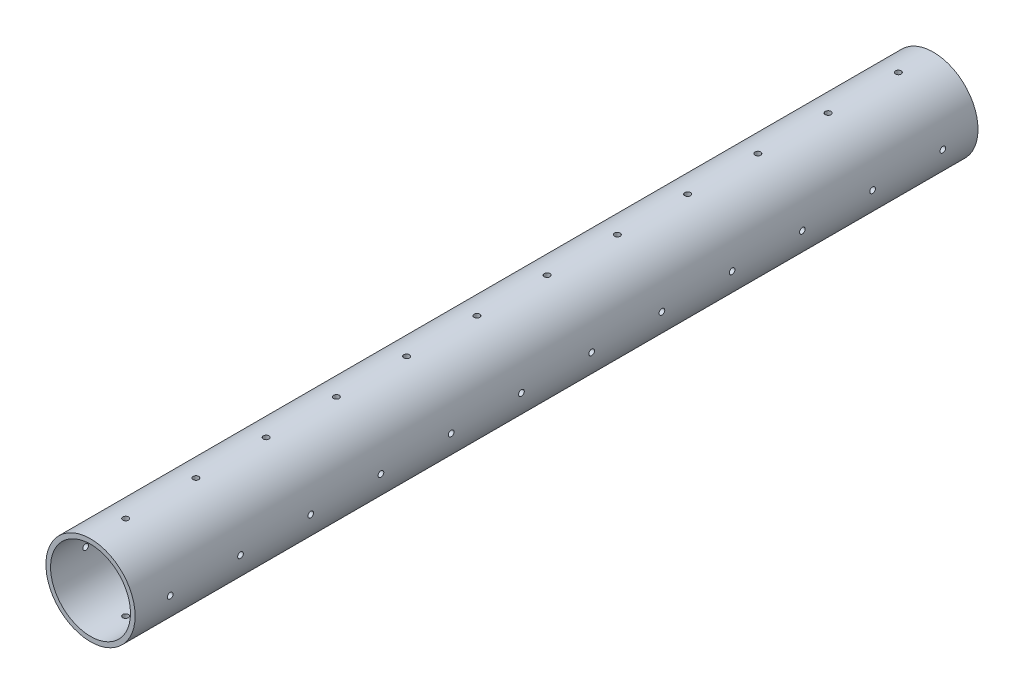
from build123d import *

# Parameters (mm, degrees)
SKETCH1_R                           = 15.875
SKETCH1_R_2                         = 14.224
BOSS_EXTRUDE1_DEPTH                 = 300
CUT_EXTRUDE1_REACH                  = 302.839
CUT_EXTRUDE1_END_RADIUS             = 15.875
SKETCH2_R                           = 1.0125
CUT_EXTRUDE1_DIRECTION_2_REACH      = 302.839
CUT_EXTRUDE1_DIRECTION_2_END_RADIUS = 15.875
CUT_EXTRUDE2_REACH                  = 302.839
CUT_EXTRUDE2_END_RADIUS             = 15.875
SKETCH3_R                           = 1.0125
CUT_EXTRUDE2_DIRECTION_2_REACH      = 302.839
CUT_EXTRUDE2_DIRECTION_2_END_RADIUS = 15.875


with BuildPart() as part:
    # Sketch1 → Boss-Extrude1 (new body)
    with BuildSketch(Plane.XY):
        Circle(SKETCH1_R)
        Circle(SKETCH1_R_2, mode=Mode.SUBTRACT)
    extrude(amount=BOSS_EXTRUDE1_DEPTH)

    # Cut-Extrude1: up to this cylinder (the profile starts inside it)
    cut_extrude1_end = Plane(origin=(0, 0, 150), z_dir=(0, 0, -1)) * Cylinder(CUT_EXTRUDE1_END_RADIUS, 913.428, mode=Mode.PRIVATE)
    # Sketch2 → Cut-Extrude1 (cut, up to the surface)
    with BuildSketch(Plane(origin=(0, 0, 0), x_dir=(1, 0, 0), z_dir=(0, 1, 0)), mode=Mode.PRIVATE) as cut_extrude1_sk1:
        with Locations((0, -12.5)):
            Circle(SKETCH2_R)
    cut_extrude1_tool1 = extrude(cut_extrude1_sk1.sketch, amount=-CUT_EXTRUDE1_REACH, mode=Mode.PRIVATE) & cut_extrude1_end
    add(cut_extrude1_tool1.solids().sort_by_distance((0, 0, 12.5))[0], mode=Mode.SUBTRACT)
    # Sketch2 → Cut-Extrude1 (cut, up to the surface)
    with BuildSketch(Plane(origin=(0, 0, 0), x_dir=(1, 0, 0), z_dir=(0, 1, 0)), mode=Mode.PRIVATE) as cut_extrude1_sk2:
        with Locations((0, -37.5)):
            Circle(SKETCH2_R)
    cut_extrude1_tool2 = extrude(cut_extrude1_sk2.sketch, amount=-CUT_EXTRUDE1_REACH, mode=Mode.PRIVATE) & cut_extrude1_end
    add(cut_extrude1_tool2.solids().sort_by_distance((0, 0, 37.5))[0], mode=Mode.SUBTRACT)
    # Sketch2 → Cut-Extrude1 (cut, up to the surface)
    with BuildSketch(Plane(origin=(0, 0, 0), x_dir=(1, 0, 0), z_dir=(0, 1, 0)), mode=Mode.PRIVATE) as cut_extrude1_sk3:
        with Locations((0, -62.5)):
            Circle(SKETCH2_R)
    cut_extrude1_tool3 = extrude(cut_extrude1_sk3.sketch, amount=-CUT_EXTRUDE1_REACH, mode=Mode.PRIVATE) & cut_extrude1_end
    add(cut_extrude1_tool3.solids().sort_by_distance((0, 0, 62.5))[0], mode=Mode.SUBTRACT)
    # Sketch2 → Cut-Extrude1 (cut, up to the surface)
    with BuildSketch(Plane(origin=(0, 0, 0), x_dir=(1, 0, 0), z_dir=(0, 1, 0)), mode=Mode.PRIVATE) as cut_extrude1_sk4:
        with Locations((0, -87.5)):
            Circle(SKETCH2_R)
    cut_extrude1_tool4 = extrude(cut_extrude1_sk4.sketch, amount=-CUT_EXTRUDE1_REACH, mode=Mode.PRIVATE) & cut_extrude1_end
    add(cut_extrude1_tool4.solids().sort_by_distance((0, 0, 87.5))[0], mode=Mode.SUBTRACT)
    # Sketch2 → Cut-Extrude1 (cut, up to the surface)
    with BuildSketch(Plane(origin=(0, 0, 0), x_dir=(1, 0, 0), z_dir=(0, 1, 0)), mode=Mode.PRIVATE) as cut_extrude1_sk5:
        with Locations((0, -112.5)):
            Circle(SKETCH2_R)
    cut_extrude1_tool5 = extrude(cut_extrude1_sk5.sketch, amount=-CUT_EXTRUDE1_REACH, mode=Mode.PRIVATE) & cut_extrude1_end
    add(cut_extrude1_tool5.solids().sort_by_distance((0, 0, 112.5))[0], mode=Mode.SUBTRACT)
    # Sketch2 → Cut-Extrude1 (cut, up to the surface)
    with BuildSketch(Plane(origin=(0, 0, 0), x_dir=(1, 0, 0), z_dir=(0, 1, 0)), mode=Mode.PRIVATE) as cut_extrude1_sk6:
        with Locations((0, -137.5)):
            Circle(SKETCH2_R)
    cut_extrude1_tool6 = extrude(cut_extrude1_sk6.sketch, amount=-CUT_EXTRUDE1_REACH, mode=Mode.PRIVATE) & cut_extrude1_end
    add(cut_extrude1_tool6.solids().sort_by_distance((0, 0, 137.5))[0], mode=Mode.SUBTRACT)
    # Sketch2 → Cut-Extrude1 (cut, up to the surface)
    with BuildSketch(Plane(origin=(0, 0, 0), x_dir=(1, 0, 0), z_dir=(0, 1, 0)), mode=Mode.PRIVATE) as cut_extrude1_sk7:
        with Locations((0, -162.5)):
            Circle(SKETCH2_R)
    cut_extrude1_tool7 = extrude(cut_extrude1_sk7.sketch, amount=-CUT_EXTRUDE1_REACH, mode=Mode.PRIVATE) & cut_extrude1_end
    add(cut_extrude1_tool7.solids().sort_by_distance((0, 0, 162.5))[0], mode=Mode.SUBTRACT)
    # Sketch2 → Cut-Extrude1 (cut, up to the surface)
    with BuildSketch(Plane(origin=(0, 0, 0), x_dir=(1, 0, 0), z_dir=(0, 1, 0)), mode=Mode.PRIVATE) as cut_extrude1_sk8:
        with Locations((0, -187.5)):
            Circle(SKETCH2_R)
    cut_extrude1_tool8 = extrude(cut_extrude1_sk8.sketch, amount=-CUT_EXTRUDE1_REACH, mode=Mode.PRIVATE) & cut_extrude1_end
    add(cut_extrude1_tool8.solids().sort_by_distance((0, 0, 187.5))[0], mode=Mode.SUBTRACT)
    # Sketch2 → Cut-Extrude1 (cut, up to the surface)
    with BuildSketch(Plane(origin=(0, 0, 0), x_dir=(1, 0, 0), z_dir=(0, 1, 0)), mode=Mode.PRIVATE) as cut_extrude1_sk9:
        with Locations((0, -212.5)):
            Circle(SKETCH2_R)
    cut_extrude1_tool9 = extrude(cut_extrude1_sk9.sketch, amount=-CUT_EXTRUDE1_REACH, mode=Mode.PRIVATE) & cut_extrude1_end
    add(cut_extrude1_tool9.solids().sort_by_distance((0, 0, 212.5))[0], mode=Mode.SUBTRACT)
    # Sketch2 → Cut-Extrude1 (cut, up to the surface)
    with BuildSketch(Plane(origin=(0, 0, 0), x_dir=(1, 0, 0), z_dir=(0, 1, 0)), mode=Mode.PRIVATE) as cut_extrude1_sk10:
        with Locations((0, -237.5)):
            Circle(SKETCH2_R)
    cut_extrude1_tool10 = extrude(cut_extrude1_sk10.sketch, amount=-CUT_EXTRUDE1_REACH, mode=Mode.PRIVATE) & cut_extrude1_end
    add(cut_extrude1_tool10.solids().sort_by_distance((0, 0, 237.5))[0], mode=Mode.SUBTRACT)
    # Sketch2 → Cut-Extrude1 (cut, up to the surface)
    with BuildSketch(Plane(origin=(0, 0, 0), x_dir=(1, 0, 0), z_dir=(0, 1, 0)), mode=Mode.PRIVATE) as cut_extrude1_sk11:
        with Locations((0, -262.5)):
            Circle(SKETCH2_R)
    cut_extrude1_tool11 = extrude(cut_extrude1_sk11.sketch, amount=-CUT_EXTRUDE1_REACH, mode=Mode.PRIVATE) & cut_extrude1_end
    add(cut_extrude1_tool11.solids().sort_by_distance((0, 0, 262.5))[0], mode=Mode.SUBTRACT)
    # Sketch2 → Cut-Extrude1 (cut, up to the surface)
    with BuildSketch(Plane(origin=(0, 0, 0), x_dir=(1, 0, 0), z_dir=(0, 1, 0)), mode=Mode.PRIVATE) as cut_extrude1_sk12:
        with Locations((0, -287.5)):
            Circle(SKETCH2_R)
    cut_extrude1_tool12 = extrude(cut_extrude1_sk12.sketch, amount=-CUT_EXTRUDE1_REACH, mode=Mode.PRIVATE) & cut_extrude1_end
    add(cut_extrude1_tool12.solids().sort_by_distance((0, 0, 287.5))[0], mode=Mode.SUBTRACT)

    # Cut-Extrude1 direction 2: up to this cylinder (the profile starts inside it)
    cut_extrude1_direction_2_end = Plane(origin=(0, 0, 150), z_dir=(0, 0, -1)) * Cylinder(CUT_EXTRUDE1_DIRECTION_2_END_RADIUS, 913.428, mode=Mode.PRIVATE)
    # Sketch2 → Cut-Extrude1 direction 2 (cut, up to the surface)
    with BuildSketch(Plane(origin=(0, 0, 0), x_dir=(1, 0, 0), z_dir=(0, 1, 0)), mode=Mode.PRIVATE) as cut_extrude1_direction_2_sk1:
        with Locations((0, -12.5)):
            Circle(SKETCH2_R)
    cut_extrude1_direction_2_tool1 = extrude(cut_extrude1_direction_2_sk1.sketch, amount=CUT_EXTRUDE1_DIRECTION_2_REACH, mode=Mode.PRIVATE) & cut_extrude1_direction_2_end
    add(cut_extrude1_direction_2_tool1.solids().sort_by_distance((0, 0, 12.5))[0], mode=Mode.SUBTRACT)
    # Sketch2 → Cut-Extrude1 direction 2 (cut, up to the surface)
    with BuildSketch(Plane(origin=(0, 0, 0), x_dir=(1, 0, 0), z_dir=(0, 1, 0)), mode=Mode.PRIVATE) as cut_extrude1_direction_2_sk2:
        with Locations((0, -37.5)):
            Circle(SKETCH2_R)
    cut_extrude1_direction_2_tool2 = extrude(cut_extrude1_direction_2_sk2.sketch, amount=CUT_EXTRUDE1_DIRECTION_2_REACH, mode=Mode.PRIVATE) & cut_extrude1_direction_2_end
    add(cut_extrude1_direction_2_tool2.solids().sort_by_distance((0, 0, 37.5))[0], mode=Mode.SUBTRACT)
    # Sketch2 → Cut-Extrude1 direction 2 (cut, up to the surface)
    with BuildSketch(Plane(origin=(0, 0, 0), x_dir=(1, 0, 0), z_dir=(0, 1, 0)), mode=Mode.PRIVATE) as cut_extrude1_direction_2_sk3:
        with Locations((0, -62.5)):
            Circle(SKETCH2_R)
    cut_extrude1_direction_2_tool3 = extrude(cut_extrude1_direction_2_sk3.sketch, amount=CUT_EXTRUDE1_DIRECTION_2_REACH, mode=Mode.PRIVATE) & cut_extrude1_direction_2_end
    add(cut_extrude1_direction_2_tool3.solids().sort_by_distance((0, 0, 62.5))[0], mode=Mode.SUBTRACT)
    # Sketch2 → Cut-Extrude1 direction 2 (cut, up to the surface)
    with BuildSketch(Plane(origin=(0, 0, 0), x_dir=(1, 0, 0), z_dir=(0, 1, 0)), mode=Mode.PRIVATE) as cut_extrude1_direction_2_sk4:
        with Locations((0, -87.5)):
            Circle(SKETCH2_R)
    cut_extrude1_direction_2_tool4 = extrude(cut_extrude1_direction_2_sk4.sketch, amount=CUT_EXTRUDE1_DIRECTION_2_REACH, mode=Mode.PRIVATE) & cut_extrude1_direction_2_end
    add(cut_extrude1_direction_2_tool4.solids().sort_by_distance((0, 0, 87.5))[0], mode=Mode.SUBTRACT)
    # Sketch2 → Cut-Extrude1 direction 2 (cut, up to the surface)
    with BuildSketch(Plane(origin=(0, 0, 0), x_dir=(1, 0, 0), z_dir=(0, 1, 0)), mode=Mode.PRIVATE) as cut_extrude1_direction_2_sk5:
        with Locations((0, -112.5)):
            Circle(SKETCH2_R)
    cut_extrude1_direction_2_tool5 = extrude(cut_extrude1_direction_2_sk5.sketch, amount=CUT_EXTRUDE1_DIRECTION_2_REACH, mode=Mode.PRIVATE) & cut_extrude1_direction_2_end
    add(cut_extrude1_direction_2_tool5.solids().sort_by_distance((0, 0, 112.5))[0], mode=Mode.SUBTRACT)
    # Sketch2 → Cut-Extrude1 direction 2 (cut, up to the surface)
    with BuildSketch(Plane(origin=(0, 0, 0), x_dir=(1, 0, 0), z_dir=(0, 1, 0)), mode=Mode.PRIVATE) as cut_extrude1_direction_2_sk6:
        with Locations((0, -137.5)):
            Circle(SKETCH2_R)
    cut_extrude1_direction_2_tool6 = extrude(cut_extrude1_direction_2_sk6.sketch, amount=CUT_EXTRUDE1_DIRECTION_2_REACH, mode=Mode.PRIVATE) & cut_extrude1_direction_2_end
    add(cut_extrude1_direction_2_tool6.solids().sort_by_distance((0, 0, 137.5))[0], mode=Mode.SUBTRACT)
    # Sketch2 → Cut-Extrude1 direction 2 (cut, up to the surface)
    with BuildSketch(Plane(origin=(0, 0, 0), x_dir=(1, 0, 0), z_dir=(0, 1, 0)), mode=Mode.PRIVATE) as cut_extrude1_direction_2_sk7:
        with Locations((0, -162.5)):
            Circle(SKETCH2_R)
    cut_extrude1_direction_2_tool7 = extrude(cut_extrude1_direction_2_sk7.sketch, amount=CUT_EXTRUDE1_DIRECTION_2_REACH, mode=Mode.PRIVATE) & cut_extrude1_direction_2_end
    add(cut_extrude1_direction_2_tool7.solids().sort_by_distance((0, 0, 162.5))[0], mode=Mode.SUBTRACT)
    # Sketch2 → Cut-Extrude1 direction 2 (cut, up to the surface)
    with BuildSketch(Plane(origin=(0, 0, 0), x_dir=(1, 0, 0), z_dir=(0, 1, 0)), mode=Mode.PRIVATE) as cut_extrude1_direction_2_sk8:
        with Locations((0, -187.5)):
            Circle(SKETCH2_R)
    cut_extrude1_direction_2_tool8 = extrude(cut_extrude1_direction_2_sk8.sketch, amount=CUT_EXTRUDE1_DIRECTION_2_REACH, mode=Mode.PRIVATE) & cut_extrude1_direction_2_end
    add(cut_extrude1_direction_2_tool8.solids().sort_by_distance((0, 0, 187.5))[0], mode=Mode.SUBTRACT)
    # Sketch2 → Cut-Extrude1 direction 2 (cut, up to the surface)
    with BuildSketch(Plane(origin=(0, 0, 0), x_dir=(1, 0, 0), z_dir=(0, 1, 0)), mode=Mode.PRIVATE) as cut_extrude1_direction_2_sk9:
        with Locations((0, -212.5)):
            Circle(SKETCH2_R)
    cut_extrude1_direction_2_tool9 = extrude(cut_extrude1_direction_2_sk9.sketch, amount=CUT_EXTRUDE1_DIRECTION_2_REACH, mode=Mode.PRIVATE) & cut_extrude1_direction_2_end
    add(cut_extrude1_direction_2_tool9.solids().sort_by_distance((0, 0, 212.5))[0], mode=Mode.SUBTRACT)
    # Sketch2 → Cut-Extrude1 direction 2 (cut, up to the surface)
    with BuildSketch(Plane(origin=(0, 0, 0), x_dir=(1, 0, 0), z_dir=(0, 1, 0)), mode=Mode.PRIVATE) as cut_extrude1_direction_2_sk10:
        with Locations((0, -237.5)):
            Circle(SKETCH2_R)
    cut_extrude1_direction_2_tool10 = extrude(cut_extrude1_direction_2_sk10.sketch, amount=CUT_EXTRUDE1_DIRECTION_2_REACH, mode=Mode.PRIVATE) & cut_extrude1_direction_2_end
    add(cut_extrude1_direction_2_tool10.solids().sort_by_distance((0, 0, 237.5))[0], mode=Mode.SUBTRACT)
    # Sketch2 → Cut-Extrude1 direction 2 (cut, up to the surface)
    with BuildSketch(Plane(origin=(0, 0, 0), x_dir=(1, 0, 0), z_dir=(0, 1, 0)), mode=Mode.PRIVATE) as cut_extrude1_direction_2_sk11:
        with Locations((0, -262.5)):
            Circle(SKETCH2_R)
    cut_extrude1_direction_2_tool11 = extrude(cut_extrude1_direction_2_sk11.sketch, amount=CUT_EXTRUDE1_DIRECTION_2_REACH, mode=Mode.PRIVATE) & cut_extrude1_direction_2_end
    add(cut_extrude1_direction_2_tool11.solids().sort_by_distance((0, 0, 262.5))[0], mode=Mode.SUBTRACT)
    # Sketch2 → Cut-Extrude1 direction 2 (cut, up to the surface)
    with BuildSketch(Plane(origin=(0, 0, 0), x_dir=(1, 0, 0), z_dir=(0, 1, 0)), mode=Mode.PRIVATE) as cut_extrude1_direction_2_sk12:
        with Locations((0, -287.5)):
            Circle(SKETCH2_R)
    cut_extrude1_direction_2_tool12 = extrude(cut_extrude1_direction_2_sk12.sketch, amount=CUT_EXTRUDE1_DIRECTION_2_REACH, mode=Mode.PRIVATE) & cut_extrude1_direction_2_end
    add(cut_extrude1_direction_2_tool12.solids().sort_by_distance((0, 0, 287.5))[0], mode=Mode.SUBTRACT)

    # Cut-Extrude2: up to this cylinder (the profile starts inside it)
    cut_extrude2_end = Plane(origin=(0, 0, 150), z_dir=(0, 0, -1)) * Cylinder(CUT_EXTRUDE2_END_RADIUS, 913.428, mode=Mode.PRIVATE)
    # Sketch3 → Cut-Extrude2 (cut, up to the surface)
    with BuildSketch(Plane(origin=(0, 0, 0), x_dir=(0, 0, -1), z_dir=(1, 0, 0)), mode=Mode.PRIVATE) as cut_extrude2_sk1:
        with Locations((-12.5, 0)):
            Circle(SKETCH3_R)
    cut_extrude2_tool1 = extrude(cut_extrude2_sk1.sketch, amount=-CUT_EXTRUDE2_REACH, mode=Mode.PRIVATE) & cut_extrude2_end
    add(cut_extrude2_tool1.solids().sort_by_distance((0, 0, 12.5))[0], mode=Mode.SUBTRACT)
    # Sketch3 → Cut-Extrude2 (cut, up to the surface)
    with BuildSketch(Plane(origin=(0, 0, 0), x_dir=(0, 0, -1), z_dir=(1, 0, 0)), mode=Mode.PRIVATE) as cut_extrude2_sk2:
        with Locations((-37.5, 0)):
            Circle(SKETCH3_R)
    cut_extrude2_tool2 = extrude(cut_extrude2_sk2.sketch, amount=-CUT_EXTRUDE2_REACH, mode=Mode.PRIVATE) & cut_extrude2_end
    add(cut_extrude2_tool2.solids().sort_by_distance((0, 0, 37.5))[0], mode=Mode.SUBTRACT)
    # Sketch3 → Cut-Extrude2 (cut, up to the surface)
    with BuildSketch(Plane(origin=(0, 0, 0), x_dir=(0, 0, -1), z_dir=(1, 0, 0)), mode=Mode.PRIVATE) as cut_extrude2_sk3:
        with Locations((-62.5, 0)):
            Circle(SKETCH3_R)
    cut_extrude2_tool3 = extrude(cut_extrude2_sk3.sketch, amount=-CUT_EXTRUDE2_REACH, mode=Mode.PRIVATE) & cut_extrude2_end
    add(cut_extrude2_tool3.solids().sort_by_distance((0, 0, 62.5))[0], mode=Mode.SUBTRACT)
    # Sketch3 → Cut-Extrude2 (cut, up to the surface)
    with BuildSketch(Plane(origin=(0, 0, 0), x_dir=(0, 0, -1), z_dir=(1, 0, 0)), mode=Mode.PRIVATE) as cut_extrude2_sk4:
        with Locations((-87.5, 0)):
            Circle(SKETCH3_R)
    cut_extrude2_tool4 = extrude(cut_extrude2_sk4.sketch, amount=-CUT_EXTRUDE2_REACH, mode=Mode.PRIVATE) & cut_extrude2_end
    add(cut_extrude2_tool4.solids().sort_by_distance((0, 0, 87.5))[0], mode=Mode.SUBTRACT)
    # Sketch3 → Cut-Extrude2 (cut, up to the surface)
    with BuildSketch(Plane(origin=(0, 0, 0), x_dir=(0, 0, -1), z_dir=(1, 0, 0)), mode=Mode.PRIVATE) as cut_extrude2_sk5:
        with Locations((-112.5, 0)):
            Circle(SKETCH3_R)
    cut_extrude2_tool5 = extrude(cut_extrude2_sk5.sketch, amount=-CUT_EXTRUDE2_REACH, mode=Mode.PRIVATE) & cut_extrude2_end
    add(cut_extrude2_tool5.solids().sort_by_distance((0, 0, 112.5))[0], mode=Mode.SUBTRACT)
    # Sketch3 → Cut-Extrude2 (cut, up to the surface)
    with BuildSketch(Plane(origin=(0, 0, 0), x_dir=(0, 0, -1), z_dir=(1, 0, 0)), mode=Mode.PRIVATE) as cut_extrude2_sk6:
        with Locations((-137.5, 0)):
            Circle(SKETCH3_R)
    cut_extrude2_tool6 = extrude(cut_extrude2_sk6.sketch, amount=-CUT_EXTRUDE2_REACH, mode=Mode.PRIVATE) & cut_extrude2_end
    add(cut_extrude2_tool6.solids().sort_by_distance((0, 0, 137.5))[0], mode=Mode.SUBTRACT)
    # Sketch3 → Cut-Extrude2 (cut, up to the surface)
    with BuildSketch(Plane(origin=(0, 0, 0), x_dir=(0, 0, -1), z_dir=(1, 0, 0)), mode=Mode.PRIVATE) as cut_extrude2_sk7:
        with Locations((-162.5, 0)):
            Circle(SKETCH3_R)
    cut_extrude2_tool7 = extrude(cut_extrude2_sk7.sketch, amount=-CUT_EXTRUDE2_REACH, mode=Mode.PRIVATE) & cut_extrude2_end
    add(cut_extrude2_tool7.solids().sort_by_distance((0, 0, 162.5))[0], mode=Mode.SUBTRACT)
    # Sketch3 → Cut-Extrude2 (cut, up to the surface)
    with BuildSketch(Plane(origin=(0, 0, 0), x_dir=(0, 0, -1), z_dir=(1, 0, 0)), mode=Mode.PRIVATE) as cut_extrude2_sk8:
        with Locations((-187.5, 0)):
            Circle(SKETCH3_R)
    cut_extrude2_tool8 = extrude(cut_extrude2_sk8.sketch, amount=-CUT_EXTRUDE2_REACH, mode=Mode.PRIVATE) & cut_extrude2_end
    add(cut_extrude2_tool8.solids().sort_by_distance((0, 0, 187.5))[0], mode=Mode.SUBTRACT)
    # Sketch3 → Cut-Extrude2 (cut, up to the surface)
    with BuildSketch(Plane(origin=(0, 0, 0), x_dir=(0, 0, -1), z_dir=(1, 0, 0)), mode=Mode.PRIVATE) as cut_extrude2_sk9:
        with Locations((-212.5, 0)):
            Circle(SKETCH3_R)
    cut_extrude2_tool9 = extrude(cut_extrude2_sk9.sketch, amount=-CUT_EXTRUDE2_REACH, mode=Mode.PRIVATE) & cut_extrude2_end
    add(cut_extrude2_tool9.solids().sort_by_distance((0, 0, 212.5))[0], mode=Mode.SUBTRACT)
    # Sketch3 → Cut-Extrude2 (cut, up to the surface)
    with BuildSketch(Plane(origin=(0, 0, 0), x_dir=(0, 0, -1), z_dir=(1, 0, 0)), mode=Mode.PRIVATE) as cut_extrude2_sk10:
        with Locations((-237.5, 0)):
            Circle(SKETCH3_R)
    cut_extrude2_tool10 = extrude(cut_extrude2_sk10.sketch, amount=-CUT_EXTRUDE2_REACH, mode=Mode.PRIVATE) & cut_extrude2_end
    add(cut_extrude2_tool10.solids().sort_by_distance((0, 0, 237.5))[0], mode=Mode.SUBTRACT)
    # Sketch3 → Cut-Extrude2 (cut, up to the surface)
    with BuildSketch(Plane(origin=(0, 0, 0), x_dir=(0, 0, -1), z_dir=(1, 0, 0)), mode=Mode.PRIVATE) as cut_extrude2_sk11:
        with Locations((-262.5, 0)):
            Circle(SKETCH3_R)
    cut_extrude2_tool11 = extrude(cut_extrude2_sk11.sketch, amount=-CUT_EXTRUDE2_REACH, mode=Mode.PRIVATE) & cut_extrude2_end
    add(cut_extrude2_tool11.solids().sort_by_distance((0, 0, 262.5))[0], mode=Mode.SUBTRACT)
    # Sketch3 → Cut-Extrude2 (cut, up to the surface)
    with BuildSketch(Plane(origin=(0, 0, 0), x_dir=(0, 0, -1), z_dir=(1, 0, 0)), mode=Mode.PRIVATE) as cut_extrude2_sk12:
        with Locations((-287.5, 0)):
            Circle(SKETCH3_R)
    cut_extrude2_tool12 = extrude(cut_extrude2_sk12.sketch, amount=-CUT_EXTRUDE2_REACH, mode=Mode.PRIVATE) & cut_extrude2_end
    add(cut_extrude2_tool12.solids().sort_by_distance((0, 0, 287.5))[0], mode=Mode.SUBTRACT)

    # Cut-Extrude2 direction 2: up to this cylinder (the profile starts inside it)
    cut_extrude2_direction_2_end = Plane(origin=(0, 0, 150), z_dir=(0, 0, -1)) * Cylinder(CUT_EXTRUDE2_DIRECTION_2_END_RADIUS, 913.428, mode=Mode.PRIVATE)
    # Sketch3 → Cut-Extrude2 direction 2 (cut, up to the surface)
    with BuildSketch(Plane(origin=(0, 0, 0), x_dir=(0, 0, -1), z_dir=(1, 0, 0)), mode=Mode.PRIVATE) as cut_extrude2_direction_2_sk1:
        with Locations((-12.5, 0)):
            Circle(SKETCH3_R)
    cut_extrude2_direction_2_tool1 = extrude(cut_extrude2_direction_2_sk1.sketch, amount=CUT_EXTRUDE2_DIRECTION_2_REACH, mode=Mode.PRIVATE) & cut_extrude2_direction_2_end
    add(cut_extrude2_direction_2_tool1.solids().sort_by_distance((0, 0, 12.5))[0], mode=Mode.SUBTRACT)
    # Sketch3 → Cut-Extrude2 direction 2 (cut, up to the surface)
    with BuildSketch(Plane(origin=(0, 0, 0), x_dir=(0, 0, -1), z_dir=(1, 0, 0)), mode=Mode.PRIVATE) as cut_extrude2_direction_2_sk2:
        with Locations((-37.5, 0)):
            Circle(SKETCH3_R)
    cut_extrude2_direction_2_tool2 = extrude(cut_extrude2_direction_2_sk2.sketch, amount=CUT_EXTRUDE2_DIRECTION_2_REACH, mode=Mode.PRIVATE) & cut_extrude2_direction_2_end
    add(cut_extrude2_direction_2_tool2.solids().sort_by_distance((0, 0, 37.5))[0], mode=Mode.SUBTRACT)
    # Sketch3 → Cut-Extrude2 direction 2 (cut, up to the surface)
    with BuildSketch(Plane(origin=(0, 0, 0), x_dir=(0, 0, -1), z_dir=(1, 0, 0)), mode=Mode.PRIVATE) as cut_extrude2_direction_2_sk3:
        with Locations((-62.5, 0)):
            Circle(SKETCH3_R)
    cut_extrude2_direction_2_tool3 = extrude(cut_extrude2_direction_2_sk3.sketch, amount=CUT_EXTRUDE2_DIRECTION_2_REACH, mode=Mode.PRIVATE) & cut_extrude2_direction_2_end
    add(cut_extrude2_direction_2_tool3.solids().sort_by_distance((0, 0, 62.5))[0], mode=Mode.SUBTRACT)
    # Sketch3 → Cut-Extrude2 direction 2 (cut, up to the surface)
    with BuildSketch(Plane(origin=(0, 0, 0), x_dir=(0, 0, -1), z_dir=(1, 0, 0)), mode=Mode.PRIVATE) as cut_extrude2_direction_2_sk4:
        with Locations((-87.5, 0)):
            Circle(SKETCH3_R)
    cut_extrude2_direction_2_tool4 = extrude(cut_extrude2_direction_2_sk4.sketch, amount=CUT_EXTRUDE2_DIRECTION_2_REACH, mode=Mode.PRIVATE) & cut_extrude2_direction_2_end
    add(cut_extrude2_direction_2_tool4.solids().sort_by_distance((0, 0, 87.5))[0], mode=Mode.SUBTRACT)
    # Sketch3 → Cut-Extrude2 direction 2 (cut, up to the surface)
    with BuildSketch(Plane(origin=(0, 0, 0), x_dir=(0, 0, -1), z_dir=(1, 0, 0)), mode=Mode.PRIVATE) as cut_extrude2_direction_2_sk5:
        with Locations((-112.5, 0)):
            Circle(SKETCH3_R)
    cut_extrude2_direction_2_tool5 = extrude(cut_extrude2_direction_2_sk5.sketch, amount=CUT_EXTRUDE2_DIRECTION_2_REACH, mode=Mode.PRIVATE) & cut_extrude2_direction_2_end
    add(cut_extrude2_direction_2_tool5.solids().sort_by_distance((0, 0, 112.5))[0], mode=Mode.SUBTRACT)
    # Sketch3 → Cut-Extrude2 direction 2 (cut, up to the surface)
    with BuildSketch(Plane(origin=(0, 0, 0), x_dir=(0, 0, -1), z_dir=(1, 0, 0)), mode=Mode.PRIVATE) as cut_extrude2_direction_2_sk6:
        with Locations((-137.5, 0)):
            Circle(SKETCH3_R)
    cut_extrude2_direction_2_tool6 = extrude(cut_extrude2_direction_2_sk6.sketch, amount=CUT_EXTRUDE2_DIRECTION_2_REACH, mode=Mode.PRIVATE) & cut_extrude2_direction_2_end
    add(cut_extrude2_direction_2_tool6.solids().sort_by_distance((0, 0, 137.5))[0], mode=Mode.SUBTRACT)
    # Sketch3 → Cut-Extrude2 direction 2 (cut, up to the surface)
    with BuildSketch(Plane(origin=(0, 0, 0), x_dir=(0, 0, -1), z_dir=(1, 0, 0)), mode=Mode.PRIVATE) as cut_extrude2_direction_2_sk7:
        with Locations((-162.5, 0)):
            Circle(SKETCH3_R)
    cut_extrude2_direction_2_tool7 = extrude(cut_extrude2_direction_2_sk7.sketch, amount=CUT_EXTRUDE2_DIRECTION_2_REACH, mode=Mode.PRIVATE) & cut_extrude2_direction_2_end
    add(cut_extrude2_direction_2_tool7.solids().sort_by_distance((0, 0, 162.5))[0], mode=Mode.SUBTRACT)
    # Sketch3 → Cut-Extrude2 direction 2 (cut, up to the surface)
    with BuildSketch(Plane(origin=(0, 0, 0), x_dir=(0, 0, -1), z_dir=(1, 0, 0)), mode=Mode.PRIVATE) as cut_extrude2_direction_2_sk8:
        with Locations((-187.5, 0)):
            Circle(SKETCH3_R)
    cut_extrude2_direction_2_tool8 = extrude(cut_extrude2_direction_2_sk8.sketch, amount=CUT_EXTRUDE2_DIRECTION_2_REACH, mode=Mode.PRIVATE) & cut_extrude2_direction_2_end
    add(cut_extrude2_direction_2_tool8.solids().sort_by_distance((0, 0, 187.5))[0], mode=Mode.SUBTRACT)
    # Sketch3 → Cut-Extrude2 direction 2 (cut, up to the surface)
    with BuildSketch(Plane(origin=(0, 0, 0), x_dir=(0, 0, -1), z_dir=(1, 0, 0)), mode=Mode.PRIVATE) as cut_extrude2_direction_2_sk9:
        with Locations((-212.5, 0)):
            Circle(SKETCH3_R)
    cut_extrude2_direction_2_tool9 = extrude(cut_extrude2_direction_2_sk9.sketch, amount=CUT_EXTRUDE2_DIRECTION_2_REACH, mode=Mode.PRIVATE) & cut_extrude2_direction_2_end
    add(cut_extrude2_direction_2_tool9.solids().sort_by_distance((0, 0, 212.5))[0], mode=Mode.SUBTRACT)
    # Sketch3 → Cut-Extrude2 direction 2 (cut, up to the surface)
    with BuildSketch(Plane(origin=(0, 0, 0), x_dir=(0, 0, -1), z_dir=(1, 0, 0)), mode=Mode.PRIVATE) as cut_extrude2_direction_2_sk10:
        with Locations((-237.5, 0)):
            Circle(SKETCH3_R)
    cut_extrude2_direction_2_tool10 = extrude(cut_extrude2_direction_2_sk10.sketch, amount=CUT_EXTRUDE2_DIRECTION_2_REACH, mode=Mode.PRIVATE) & cut_extrude2_direction_2_end
    add(cut_extrude2_direction_2_tool10.solids().sort_by_distance((0, 0, 237.5))[0], mode=Mode.SUBTRACT)
    # Sketch3 → Cut-Extrude2 direction 2 (cut, up to the surface)
    with BuildSketch(Plane(origin=(0, 0, 0), x_dir=(0, 0, -1), z_dir=(1, 0, 0)), mode=Mode.PRIVATE) as cut_extrude2_direction_2_sk11:
        with Locations((-262.5, 0)):
            Circle(SKETCH3_R)
    cut_extrude2_direction_2_tool11 = extrude(cut_extrude2_direction_2_sk11.sketch, amount=CUT_EXTRUDE2_DIRECTION_2_REACH, mode=Mode.PRIVATE) & cut_extrude2_direction_2_end
    add(cut_extrude2_direction_2_tool11.solids().sort_by_distance((0, 0, 262.5))[0], mode=Mode.SUBTRACT)
    # Sketch3 → Cut-Extrude2 direction 2 (cut, up to the surface)
    with BuildSketch(Plane(origin=(0, 0, 0), x_dir=(0, 0, -1), z_dir=(1, 0, 0)), mode=Mode.PRIVATE) as cut_extrude2_direction_2_sk12:
        with Locations((-287.5, 0)):
            Circle(SKETCH3_R)
    cut_extrude2_direction_2_tool12 = extrude(cut_extrude2_direction_2_sk12.sketch, amount=CUT_EXTRUDE2_DIRECTION_2_REACH, mode=Mode.PRIVATE) & cut_extrude2_direction_2_end
    add(cut_extrude2_direction_2_tool12.solids().sort_by_distance((0, 0, 287.5))[0], mode=Mode.SUBTRACT)


solid = part.part
